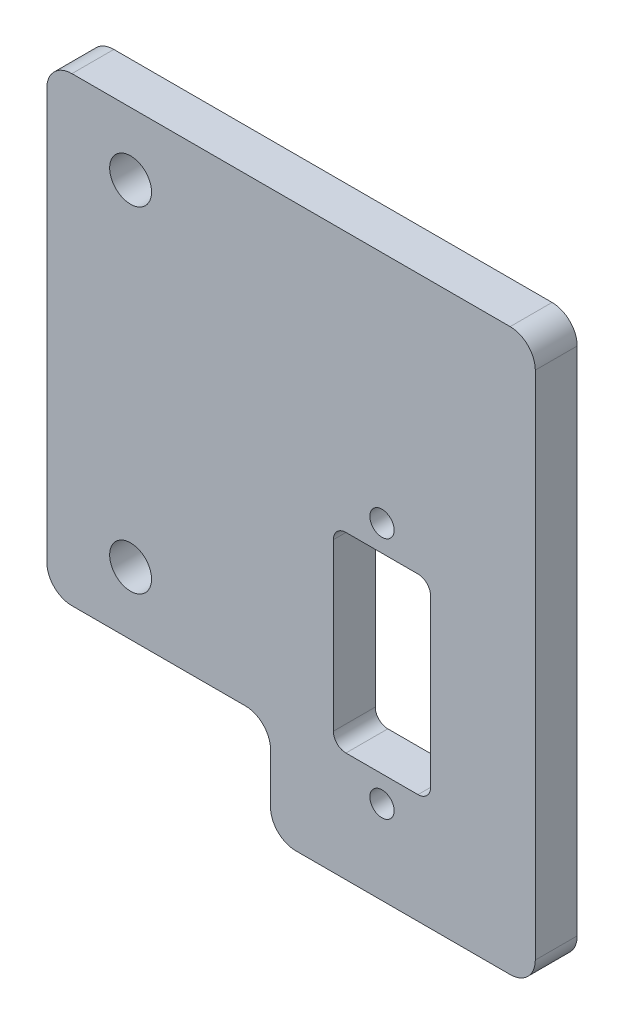
from build123d import *

# Parameters (mm, degrees)
BASE_W                 = 11.6
BASE_H                 = 22.8
MAIN_DEPTH             = 5
GEAR_AXIS_HOLES_D      = 5
M2_5_CLEARANCE_HOLE1_D = 2.9
FILLET1_R              = 3
FILLET2_R              = 1.5


with BuildPart() as part:
    # Base → Main (new body)
    with BuildSketch(Plane.XY):
        Polygon((0, 27.5), (-26.7, 27.5), (-26.7, -27.5), (0, -27.5), (0, -39.47), (26.6, -39.47), (31.6, -39.47), (31.6, 27.5), (26.6, 27.5), align=None)
        with Locations((13.3, -14.97)):
            Rectangle(BASE_W, BASE_H, mode=Mode.SUBTRACT)
    extrude(amount=MAIN_DEPTH)

    # Gear Axis Holes (through all)
    with Locations(Plane(origin=(0, 0, 0), x_dir=(-1, 0, 0), z_dir=(0, 0, -1))):
        with Locations((16.7, -20), (16.7, 20)):
            Hole(GEAR_AXIS_HOLES_D / 2)

    # M2.5 Clearance Hole1 (through all)
    with Locations(Plane.XY.offset(5)):
        with Locations((13.3, -0.47), (13.3, -29.47)):
            Hole(M2_5_CLEARANCE_HOLE1_D / 2)

    # Fillet1
    fillet1_edges = [part.edges().sort_by_distance(p)[0] for p in [
        (31.6, 27.5, 2.5),
        (31.6, -39.47, 2.5),
        (0, -39.47, 2.5),
        (0, -27.5, 2.5),
        (-26.7, -27.5, 2.5),
        (-26.7, 27.5, 2.5),
    ]]
    fillet(fillet1_edges, radius=FILLET1_R)

    # Fillet2
    fillet2_edges = [part.edges().sort_by_distance(p)[0] for p in [
        (19.1, -26.37, 2.5),
        (19.1, -3.57, 2.5),
        (7.5, -3.57, 2.5),
        (7.5, -26.37, 2.5),
    ]]
    fillet(fillet2_edges, radius=FILLET2_R)


solid = part.part
